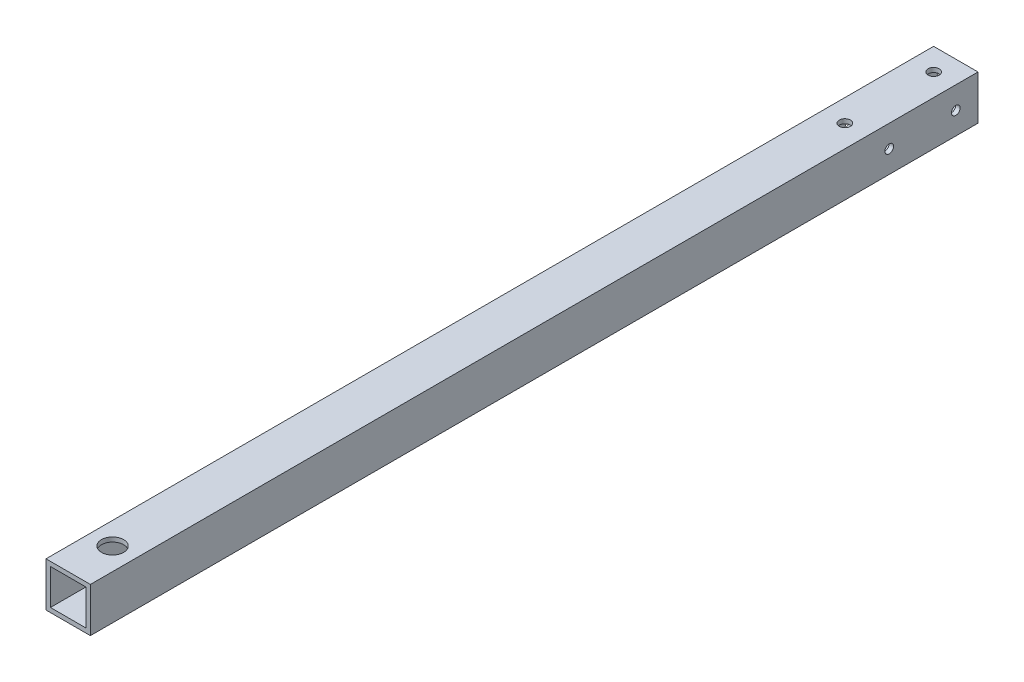
from build123d import *

# Parameters (mm, degrees)
SKETCH1_W           = 25.4
SKETCH1_H           = 25.4
SKETCH1_W_2         = 20.32
SKETCH1_H_2         = 20.32
EXTRUDE_THIN1_DEPTH = 254
SKETCH2_R           = 3.175
CUT_EXTRUDE1_DEPTH  = 26.4
SKETCH3_R           = 6.35
CUT_EXTRUDE2_DEPTH  = 26.4
SKETCH4_R           = 2.4892
CUT_EXTRUDE3_DEPTH  = 26.4


with BuildPart() as part:
    # Sketch1 → Extrude-Thin1 (new body, symmetric)
    with BuildSketch(Plane.XY):
        Rectangle(SKETCH1_W, SKETCH1_H)
        Rectangle(SKETCH1_W_2, SKETCH1_H_2, mode=Mode.SUBTRACT)
    extrude(amount=EXTRUDE_THIN1_DEPTH, both=True)

    # Sketch2 → Cut-Extrude1 (cut, through all)
    with BuildSketch(Plane(origin=(0, 12.7, 0), x_dir=(1, 0, 0), z_dir=(0, 1, 0))):
        with Locations((0, 241.3)):
            Circle(SKETCH2_R)
        with Locations((0, 190.5)):
            Circle(SKETCH2_R)
    extrude(amount=-CUT_EXTRUDE1_DEPTH, mode=Mode.SUBTRACT)

    # Sketch3 → Cut-Extrude2 (cut, through all)
    with BuildSketch(Plane(origin=(0, 12.7, 0), x_dir=(1, 0, 0), z_dir=(0, 1, 0))):
        with Locations((0, -228.6)):
            Circle(SKETCH3_R)
    extrude(amount=-CUT_EXTRUDE2_DEPTH, mode=Mode.SUBTRACT)

    # Sketch4 → Cut-Extrude3 (cut, through all)
    with BuildSketch(Plane.ZY.offset(12.7)):
        with Locations((-241.3, 0)):
            Circle(SKETCH4_R)
        with Locations((-203.2, 0)):
            Circle(SKETCH4_R)
    extrude(amount=-CUT_EXTRUDE3_DEPTH, mode=Mode.SUBTRACT)


solid = part.part
